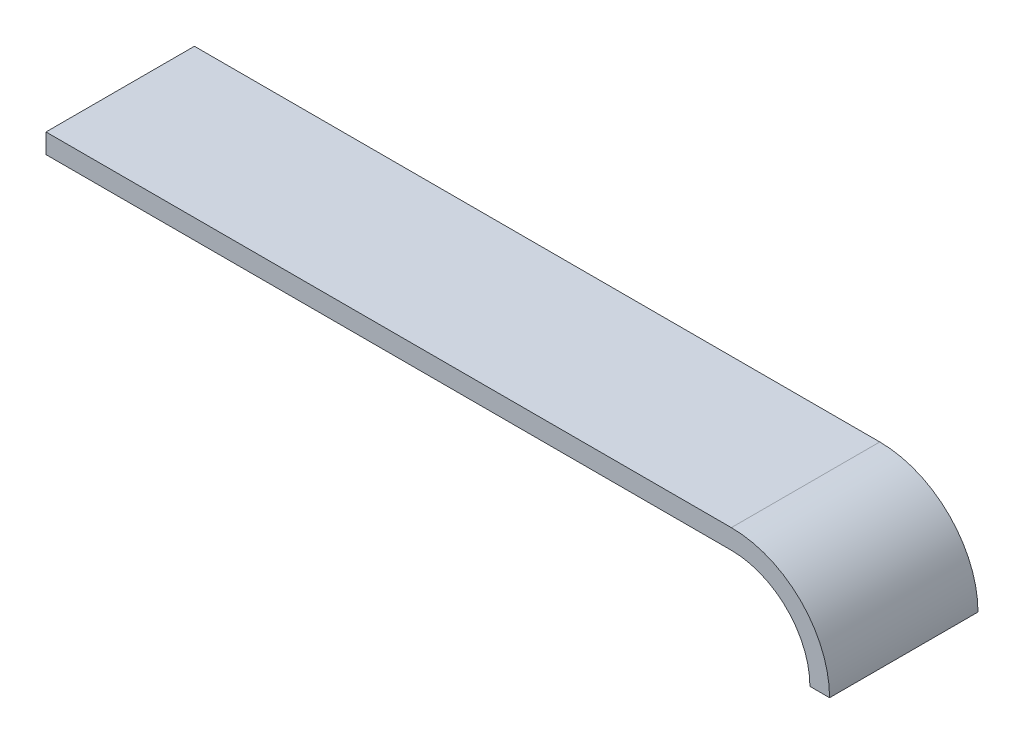
from build123d import *

# Parameters (mm, degrees)
BOSS_EXTRUDE1_DEPTH = 17


with BuildPart() as part:
    # Sketch2 → Boss-Extrude1 (new body)
    with BuildSketch(Plane.XY):
        with BuildLine():
            Line((35.613241121, -15.95389552), (37.863241121, -15.95389552))
            ThreePointArc((37.863241121, -15.95389552), (34.568192409, -7.998944231), (26.613241121, -4.70389552))
            Line((26.613241121, -4.70389552), (-51.886758879, -4.70389552))
            Line((-51.886758879, -4.70389552), (-51.886758879, -6.95389552))
            Line((-51.886758879, -6.95389552), (26.613241121, -6.95389552))
            ThreePointArc((26.613241121, -6.95389552), (32.977202152, -9.589934489), (35.613241121, -15.95389552))
        make_face()
    extrude(amount=BOSS_EXTRUDE1_DEPTH)


solid = part.part
